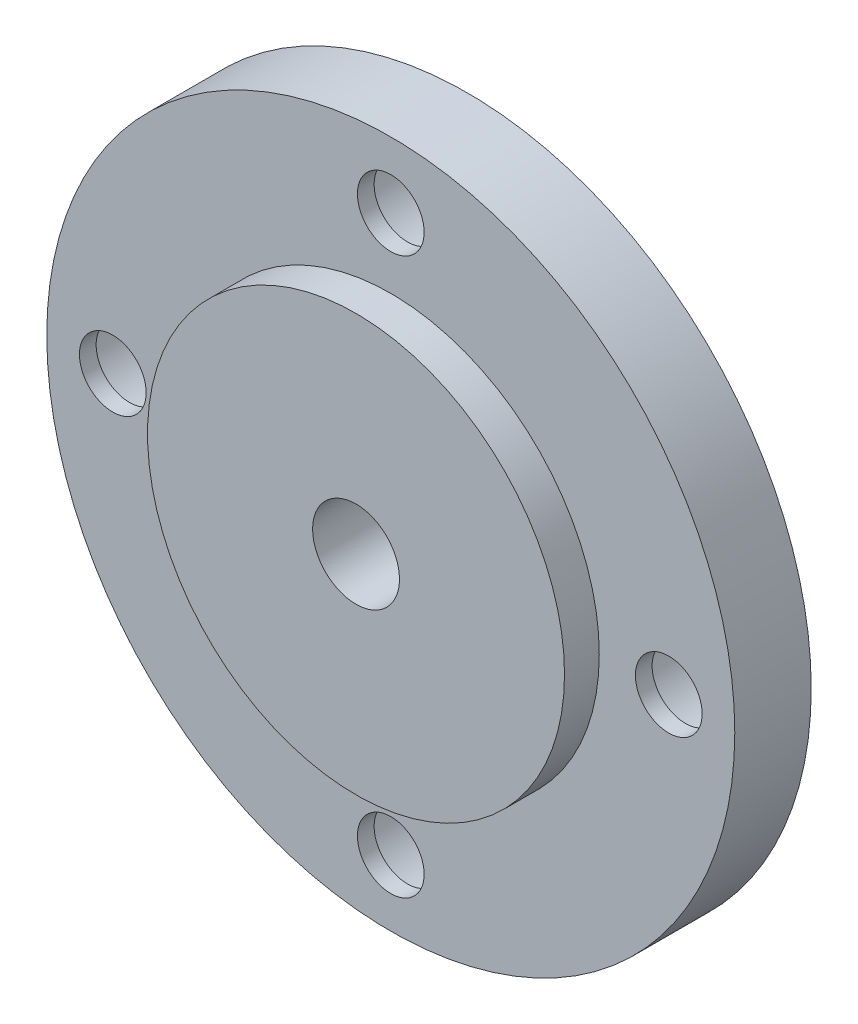
from build123d import *

# Parameters (mm, degrees)
SKETCH1_R                  = 12.573
BOSS_EXTRUDE1_DEPTH        = 2.794
SKETCH2_R                  = 7.62
BOSS_EXTRUDE2_DEPTH        = 1.27
CIRPATTERN2_COUNT          = 4
F_1_8_0_1250_DOWEL_HOLE2_D = 3.175


with BuildPart() as part:
    # Sketch1 → Boss-Extrude1 (new body)
    with BuildSketch(Plane.XY):
        Circle(SKETCH1_R)
    extrude(amount=BOSS_EXTRUDE1_DEPTH)

    # Sketch2 → Boss-Extrude2 (add)
    with BuildSketch(Plane.XY.offset(2.794)):
        Circle(SKETCH2_R)
    extrude(amount=BOSS_EXTRUDE2_DEPTH)

    # Sketch18 → CBORE for _2 Socket Head Cap Screw1 (revolve, cut)
    with BuildSketch(Plane.YZ.offset(-10.16)):
        Polygon((0, 0), (0, 8.446549267), (1.2192, 7.71398), (1.2192, 2.1844), (2.38125, 2.1844), (2.38125, 0), align=None)
    cbore_for_2_socket_head_cap_screw1 = revolve(axis=Axis((-10.16, 0, -6.35), (0, 0, 1)), mode=Mode.SUBTRACT)

    # CirPattern2: CBORE for _2 Socket Head Cap Screw1 ×4 about axis
    cirpattern2_axis = Axis((0, 0, 0), (0, 0, -1))
    for i in range(1, CIRPATTERN2_COUNT):
        add(cbore_for_2_socket_head_cap_screw1.rotate(cirpattern2_axis, i * 360 / CIRPATTERN2_COUNT), mode=Mode.SUBTRACT)

    # 1_8 _0.1250_ Dowel Hole2 (through all)
    with Locations(Plane(origin=(0, 0, 0), x_dir=(-1, 0, 0), z_dir=(0, 0, -1))):
        with Locations((0, 0)):
            Hole(F_1_8_0_1250_DOWEL_HOLE2_D / 2)


solid = part.part
